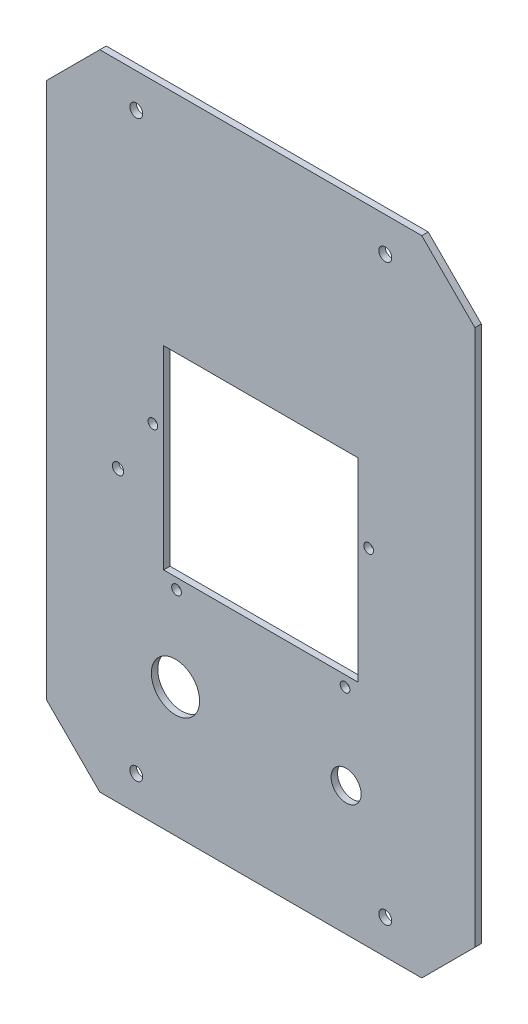
from build123d import *

# Parameters (mm, degrees)
BASE_DEPTH              = 3
ESQUISSE2_R             = 3
ENL_V_MAT_EXTRU_1_DEPTH = 4
ENL_V_MAT_EXTRU_2_REACH = 5
ESQUISSE3_R             = 11.25
ESQUISSE3_R_2           = 7
ENL_V_MAT_EXTRU_3_REACH = 5
ESQUISSE4_R             = 2.625
ENL_V_MAT_EXTRU_4_REACH = 5
ESQUISSE5_W             = 90.5
ESQUISSE5_H             = 90.5
ESQUISSE6_R             = 2.25
ENL_V_MAT_EXTRU_5_DEPTH = 10


with BuildPart() as part:
    # Esquisse1 → Base (new body)
    with BuildSketch(Plane.XY):
        Polygon((24.748737342, 24.748737342), (0, 0), (-150, 0), (-174.748737342, 24.748737342), (-174.748737342, 274.748737342), (-150, 299.497474683), (0, 299.497474683), (24.748737342, 274.748737342), align=None)
    extrude(amount=BASE_DEPTH)

    # Esquisse2 → Enlèv. mat.-Extru.1 (cut, through all)
    with BuildSketch(Plane(origin=(0, 0, 0), x_dir=(-1, 0, 0), z_dir=(0, 0, -1))):
        with Locations((132.998737342, 283.497474683)):
            Circle(ESQUISSE2_R)
        with Locations((132.998737342, 16)):
            Circle(ESQUISSE2_R)
        with Locations((17.001262658, 16)):
            Circle(ESQUISSE2_R)
        with Locations((17.001262658, 283.497474683)):
            Circle(ESQUISSE2_R)
    extrude(amount=-ENL_V_MAT_EXTRU_1_DEPTH, mode=Mode.SUBTRACT)

    # Esquisse3 → Enlèv. mat.-Extru.2 (cut, up to next)
    with BuildSketch(Plane(origin=(0, 0, 0), x_dir=(-1, 0, 0), z_dir=(0, 0, -1)), mode=Mode.PRIVATE) as enl_v_mat_extru_2_sk1:
        with Locations((114.748737342, 60)):
            Circle(ESQUISSE3_R)
    enl_v_mat_extru_2_tool1 = extrude(enl_v_mat_extru_2_sk1.sketch, amount=-ENL_V_MAT_EXTRU_2_REACH, mode=Mode.PRIVATE) & part.part
    add(enl_v_mat_extru_2_tool1.solids().sort_by_distance((-114.748737, 60, 0))[0], mode=Mode.SUBTRACT)
    # Esquisse3 → Enlèv. mat.-Extru.2 (cut, up to next)
    with BuildSketch(Plane(origin=(0, 0, 0), x_dir=(-1, 0, 0), z_dir=(0, 0, -1)), mode=Mode.PRIVATE) as enl_v_mat_extru_2_sk2:
        with Locations((35.251262658, 60)):
            Circle(ESQUISSE3_R_2)
    enl_v_mat_extru_2_tool2 = extrude(enl_v_mat_extru_2_sk2.sketch, amount=-ENL_V_MAT_EXTRU_2_REACH, mode=Mode.PRIVATE) & part.part
    add(enl_v_mat_extru_2_tool2.solids().sort_by_distance((-35.251263, 60, 0))[0], mode=Mode.SUBTRACT)

    # Esquisse4 → Enlèv. mat.-Extru.3 (cut, up to next)
    with BuildSketch(Plane(origin=(0, 0, 0), x_dir=(-1, 0, 0), z_dir=(0, 0, -1)), mode=Mode.PRIVATE) as enl_v_mat_extru_3_sk1:
        with Locations((141.498737342, 134.75)):
            Circle(ESQUISSE4_R)
    enl_v_mat_extru_3_tool1 = extrude(enl_v_mat_extru_3_sk1.sketch, amount=-ENL_V_MAT_EXTRU_3_REACH, mode=Mode.PRIVATE) & part.part
    add(enl_v_mat_extru_3_tool1.solids().sort_by_distance((-141.498737, 134.75, 0))[0], mode=Mode.SUBTRACT)

    # Esquisse5 → Enlèv. mat.-Extru.4 (cut, up to next)
    with BuildSketch(Plane.XY.offset(3), mode=Mode.PRIVATE) as enl_v_mat_extru_4_sk1:
        with Locations((-75, 149.748737342)):
            Rectangle(ESQUISSE5_W, ESQUISSE5_H)
    enl_v_mat_extru_4_tool1 = extrude(enl_v_mat_extru_4_sk1.sketch, amount=-ENL_V_MAT_EXTRU_4_REACH, mode=Mode.PRIVATE) & part.part
    add(enl_v_mat_extru_4_tool1.solids().sort_by_distance((-75, 149.748737, 3))[0], mode=Mode.SUBTRACT)

    # Esquisse6 → Enlèv. mat.-Extru.5 (cut)
    with BuildSketch(Plane(origin=(0, 0, 0), x_dir=(-1, 0, 0), z_dir=(0, 0, -1))):
        with Locations((125.25, 160.998737342)):
            Circle(ESQUISSE6_R)
        with Locations((35.75, 99.498737342)):
            Circle(ESQUISSE6_R)
        with Locations((114.25, 99.498737342)):
            Circle(ESQUISSE6_R)
        with Locations((24.75, 160.998737342)):
            Circle(ESQUISSE6_R)
    extrude(amount=-ENL_V_MAT_EXTRU_5_DEPTH, mode=Mode.SUBTRACT)


solid = part.part
